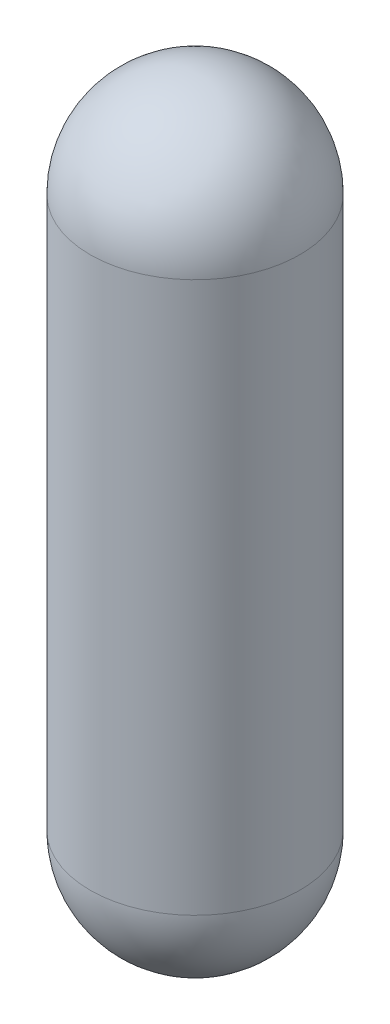
from build123d import *

# Parameters (mm, degrees)
SKETCH1_R      = 50.8
EXTRUDE1_DEPTH = 266.7


with BuildPart() as part:
    # Sketch1 → Extrude1 (new body)
    with BuildSketch(Plane(origin=(0, 0, 0), x_dir=(1, 0, 0), z_dir=(0, 1, 0))):
        Circle(SKETCH1_R)
    extrude(amount=EXTRUDE1_DEPTH)

    # Sketch5 → Revolve1 (revolve)
    with BuildSketch(Plane(origin=(0, 0, 0), x_dir=(0, 0, -1), z_dir=(1, 0, 0))):
        with BuildLine():
            Line((0, 0), (-50.8, 0))
            ThreePointArc((-50.8, 0), (-35.921024484, -35.921024484), (0, -50.8))
            Line((0, -50.8), (0, 0))
        make_face()
        with BuildLine():
            Line((0, 317.5), (0, 266.7))
            Line((0, 266.7), (-50.8, 266.7))
            ThreePointArc((-50.8, 266.7), (-35.921024484, 302.621024484), (0, 317.5))
        make_face()
    revolve(axis=Axis((0, 266.7, 0), (0, -1, 0)))


solid = part.part
